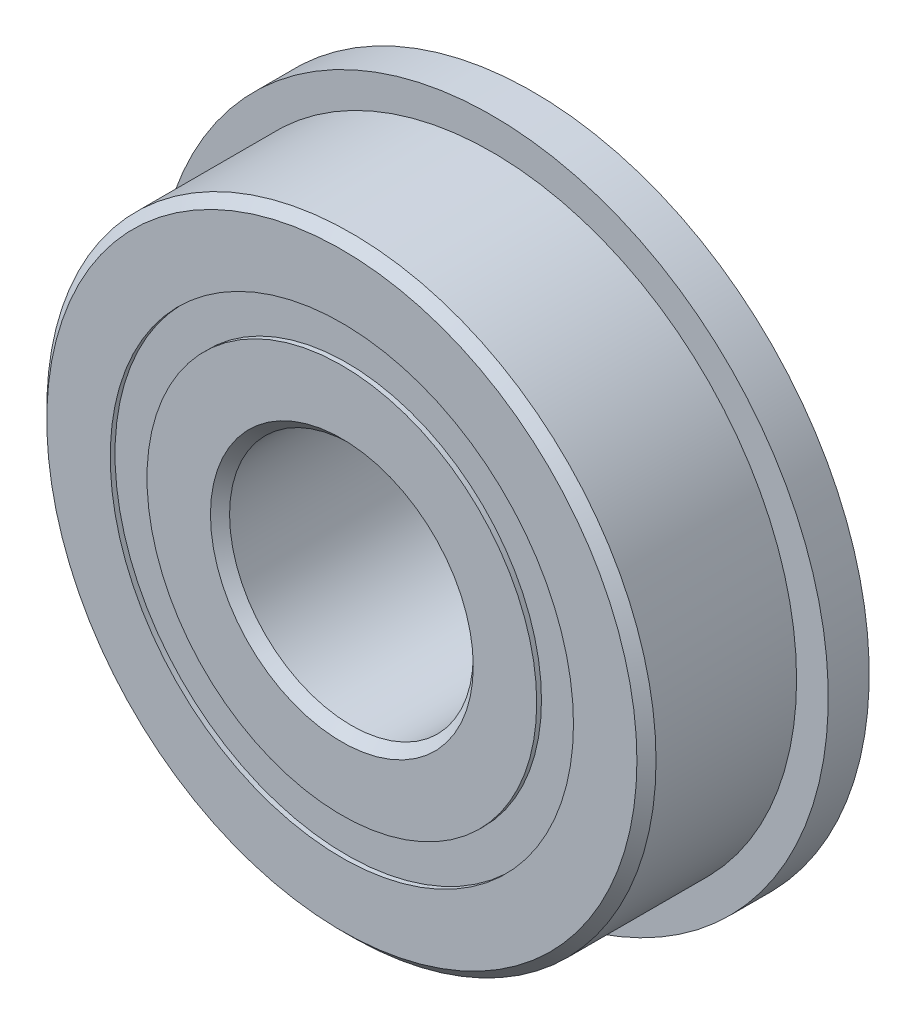
from build123d import *

# Parameters (mm, degrees)
CIRPATTERN1_COUNT = 12
SKETCH5_W         = 1.15919535
SKETCH5_H         = 0.957942858
SKETCH6_W         = 1.0668
SKETCH6_H         = 2.727778571


with BuildPart() as part:
    # Sketch1 → Revolve1 (revolve)
    with BuildSketch(Plane(origin=(0, 0, 0), x_dir=(0, 0, -1), z_dir=(1, 0, 0))):
        with BuildLine():
            Line((2.24028, 7.9375), (-2.24028, 7.9375))
            Line((-2.24028, 7.9375), (-2.4892, 7.68858))
            Line((-2.4892, 7.68858), (-2.4892, 6.035221429))
            Line((-2.4892, 6.035221429), (-1.106311111, 6.035221429))
            ThreePointArc((-1.106311111, 6.035221429), (0, 6.76179465), (1.106311111, 6.035221429))
            Line((1.106311111, 6.035221429), (2.4892, 6.035221429))
            Line((2.4892, 6.035221429), (2.4892, 7.68858))
            Line((2.4892, 7.68858), (2.24028, 7.9375))
        make_face()
    revolve(axis=Axis((0, 0, 2.4892), (0, 0, -1)))

    # Sketch6 → Revolve6 (revolve)
    with BuildSketch(Plane(origin=(0, 0, 0), x_dir=(0, 0, -1), z_dir=(1, 0, 0))):
        with Locations((1.9558, 7.399110715)):
            Rectangle(SKETCH6_W, SKETCH6_H)
    revolve(axis=Axis((0, 0, -2.4892), (0, 0, 1)))


with BuildPart() as body_2:
    # Sketch3 → Revolve3 (revolve)
    with BuildSketch(Plane(origin=(0, 0, 0), x_dir=(0, 0, -1), z_dir=(1, 0, 0))):
        with BuildLine():
            Line((-2.4892, 5.077278571), (-1.106311111, 5.077278571))
            ThreePointArc((-1.106311111, 5.077278571), (0, 4.35070535), (1.106311111, 5.077278571))
            Line((1.106311111, 5.077278571), (2.4892, 5.077278571))
            Line((2.4892, 5.077278571), (2.4892, 3.42392))
            Line((2.4892, 3.42392), (2.24028, 3.175))
            Line((2.24028, 3.175), (-2.24028, 3.175))
            Line((-2.24028, 3.175), (-2.4892, 3.42392))
            Line((-2.4892, 3.42392), (-2.4892, 5.077278571))
        make_face()
    revolve(axis=Axis((0, 0, 2.4892), (0, 0, -1)))


with BuildPart() as body_3:
    # Sketch4 → Revolve4 (revolve)
    with BuildSketch(Plane(origin=(0, 0, 0), x_dir=(0, 0, -1), z_dir=(1, 0, 0))):
        with BuildLine():
            Line((-1.20554465, 5.55625), (1.20554465, 5.55625))
            ThreePointArc((1.20554465, 5.55625), (0, 6.76179465), (-1.20554465, 5.55625))
        make_face()
    revolve(axis=Axis((0, 5.55625, 1.20554465), (0, 0, -1)))


with BuildPart() as cirpattern1_1:
    # CirPattern1: pattern copy
    add(body_3.part.rotate(Axis((0, 0, -2.4892), (0, 0, 1)), 1 * 360 / CIRPATTERN1_COUNT))


with BuildPart() as cirpattern1_2:
    # CirPattern1: pattern copy
    add(body_3.part.rotate(Axis((0, 0, -2.4892), (0, 0, 1)), 2 * 360 / CIRPATTERN1_COUNT))


with BuildPart() as cirpattern1_3:
    # CirPattern1: pattern copy
    add(body_3.part.rotate(Axis((0, 0, -2.4892), (0, 0, 1)), 3 * 360 / CIRPATTERN1_COUNT))


with BuildPart() as cirpattern1_4:
    # CirPattern1: pattern copy
    add(body_3.part.rotate(Axis((0, 0, -2.4892), (0, 0, 1)), 4 * 360 / CIRPATTERN1_COUNT))


with BuildPart() as cirpattern1_5:
    # CirPattern1: pattern copy
    add(body_3.part.rotate(Axis((0, 0, -2.4892), (0, 0, 1)), 5 * 360 / CIRPATTERN1_COUNT))


with BuildPart() as cirpattern1_6:
    # CirPattern1: pattern copy
    add(body_3.part.rotate(Axis((0, 0, -2.4892), (0, 0, 1)), 6 * 360 / CIRPATTERN1_COUNT))


with BuildPart() as cirpattern1_7:
    # CirPattern1: pattern copy
    add(body_3.part.rotate(Axis((0, 0, -2.4892), (0, 0, 1)), 7 * 360 / CIRPATTERN1_COUNT))


with BuildPart() as cirpattern1_8:
    # CirPattern1: pattern copy
    add(body_3.part.rotate(Axis((0, 0, -2.4892), (0, 0, 1)), 8 * 360 / CIRPATTERN1_COUNT))


with BuildPart() as cirpattern1_9:
    # CirPattern1: pattern copy
    add(body_3.part.rotate(Axis((0, 0, -2.4892), (0, 0, 1)), 9 * 360 / CIRPATTERN1_COUNT))


with BuildPart() as cirpattern1_10:
    # CirPattern1: pattern copy
    add(body_3.part.rotate(Axis((0, 0, -2.4892), (0, 0, 1)), 10 * 360 / CIRPATTERN1_COUNT))


with BuildPart() as cirpattern1_11:
    # CirPattern1: pattern copy
    add(body_3.part.rotate(Axis((0, 0, -2.4892), (0, 0, 1)), 11 * 360 / CIRPATTERN1_COUNT))


with BuildPart() as body_15:
    # Sketch5 → Revolve5 (revolve)
    with BuildSketch(Plane(origin=(0, 0, 0), x_dir=(0, 0, -1), z_dir=(1, 0, 0))):
        with Locations((-1.785142325, 5.55625)):
            Rectangle(SKETCH5_W, SKETCH5_H)
        with Locations((1.785142325, 5.55625)):
            Rectangle(SKETCH5_W, SKETCH5_H)
    revolve(axis=Axis((0, 0, 2.4892), (0, 0, -1)))


solid = Compound([part.part, body_2.part, body_3.part, cirpattern1_1.part, cirpattern1_2.part, cirpattern1_3.part, cirpattern1_4.part, cirpattern1_5.part, cirpattern1_6.part, cirpattern1_7.part, cirpattern1_8.part, cirpattern1_9.part, cirpattern1_10.part, cirpattern1_11.part, body_15.part])
